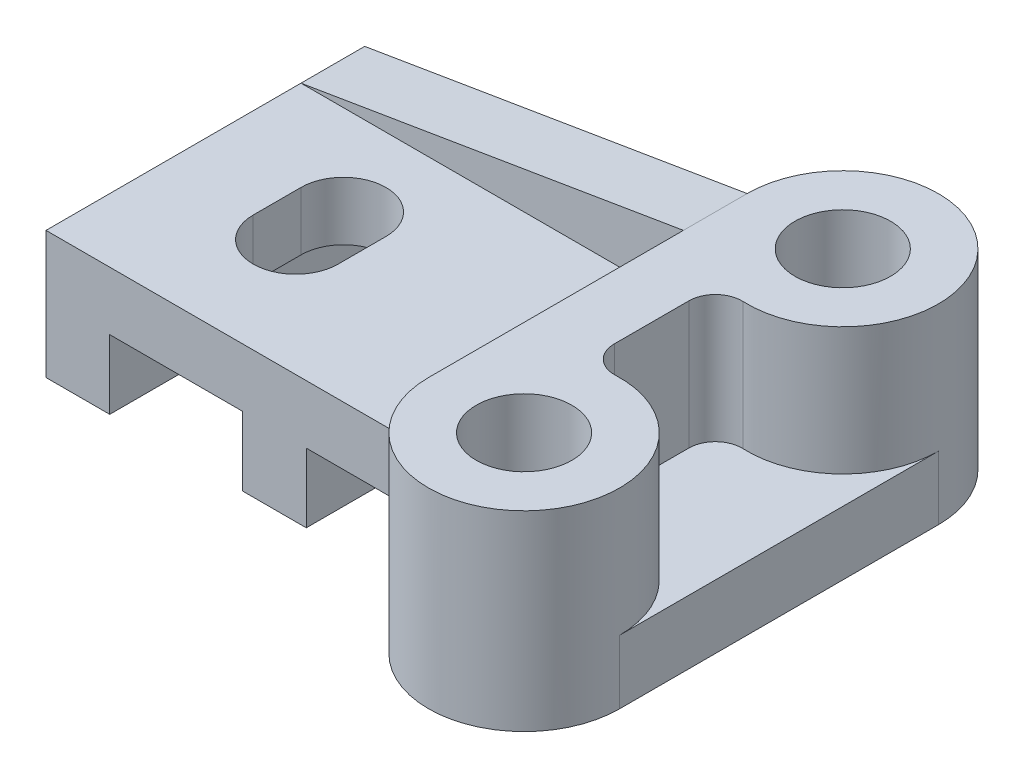
from build123d import *

# Parameters (mm, degrees)
BOSS_EXTRUDE1_DEPTH      = 30
SKETCH2_R                = 9
BOSS_EXTRUDE2_DEPTH      = 12
BOSS_EXTRUDE2_DEPTH_BACK = 24
FILLET1_R                = 5
BOSS_EXTRUDE3_DEPTH      = 12
RIB1_REACH               = 80
SKETCH4_WALL_W           = 230.993150364
SKETCH4_WALL_H           = 12
CUT_EXTRUDE1_DEPTH       = 25


with BuildPart() as part:
    # Sketch1 → Boss-Extrude1 (new body, symmetric)
    with BuildSketch(Plane.XY):
        Polygon((0, 0), (0, 24), (72, 24), (72, 13), (49, 13), (49, 0), (37, 0), (37, 13), (12, 13), (12, 0), align=None)
    extrude(amount=BOSS_EXTRUDE1_DEPTH, both=True)

    # Sketch2 → Boss-Extrude2 (add, two sides)
    with BuildSketch(Plane(origin=(0, 24, 0), x_dir=(1, 0, 0), z_dir=(0, 1, 0))) as boss_extrude2_sk:
        with BuildLine():
            Line((72, 30), (72, -30))
            ThreePointArc((72, -30), (104.696938457, -40.392304845), (84, -13.029437252))
            Line((84, -13.029437252), (84, 13.029437252))
            ThreePointArc((84, 13.029437252), (104.696938457, 40.392304845), (72, 30))
        make_face()
        with Locations(Location((90, 30, 0), (0, 0, 270))):  # turned: the seam where the file's is
            Circle(SKETCH2_R, mode=Mode.SUBTRACT)
        with Locations(Location((90, -30, 0), (0, 0, 270))):  # turned: the seam where the file's is
            Circle(SKETCH2_R, mode=Mode.SUBTRACT)
    extrude(amount=BOSS_EXTRUDE2_DEPTH)
    extrude(boss_extrude2_sk.sketch, amount=-BOSS_EXTRUDE2_DEPTH_BACK)

    # Fillet1
    fillet1_edges = [part.edges().sort_by_distance(p)[0] for p in [
        (84, 18, -13.029437252),
        (84, 18, 13.029437252),
    ]]
    fillet(fillet1_edges, radius=FILLET1_R)

    # Sketch3 → Boss-Extrude3 (add)
    with BuildSketch(Plane.XZ):
        with BuildLine():
            Line((108, 30), (108, -30))
            ThreePointArc((108, -30), (102.448153347, -16.998327867), (89.217391304, -12.01702128))
            ThreePointArc((89.217391304, -12.01702128), (85.542179626, -10.633325006), (84, -7.021749414))
            Line((84, -7.021749414), (84, 7.021749414))
            ThreePointArc((84, 7.021749414), (85.542179626, 10.633325006), (89.217391304, 12.01702128))
            ThreePointArc((89.217391304, 12.01702128), (102.448153347, 16.998327867), (108, 30))
        make_face()
    extrude(amount=-BOSS_EXTRUDE3_DEPTH)

    # Sketch4 wall → Rib1 (add, up to next)
    with BuildSketch(Plane(origin=(36, 30, -30), x_dir=(-0.986393924, -0.164398987, 0), z_dir=(-0.164398987, 0.986393924, 0)), mode=Mode.PRIVATE) as rib1_sk1:
        with Locations((0, 6)):
            Rectangle(SKETCH4_WALL_W, SKETCH4_WALL_H)
    rib1_tool1 = extrude(rib1_sk1.sketch, amount=-RIB1_REACH, mode=Mode.PRIVATE) - part.part
    add(rib1_tool1.solids().sort_by_distance((36, 30, -30))[0])

    # Sketch5 → Cut-Extrude1 (cut, through all)
    with BuildSketch(Plane(origin=(0, 24, 0), x_dir=(1, 0, 0), z_dir=(0, 1, 0))):
        with BuildLine():
            Line((33, 1), (33, -8))
            ThreePointArc((33, -8), (25, -16), (17, -8))
            Line((17, -8), (17, 1))
            ThreePointArc((17, 1), (25, 9), (33, 1))
        make_face()
    extrude(amount=-CUT_EXTRUDE1_DEPTH, mode=Mode.SUBTRACT)


solid = part.part
